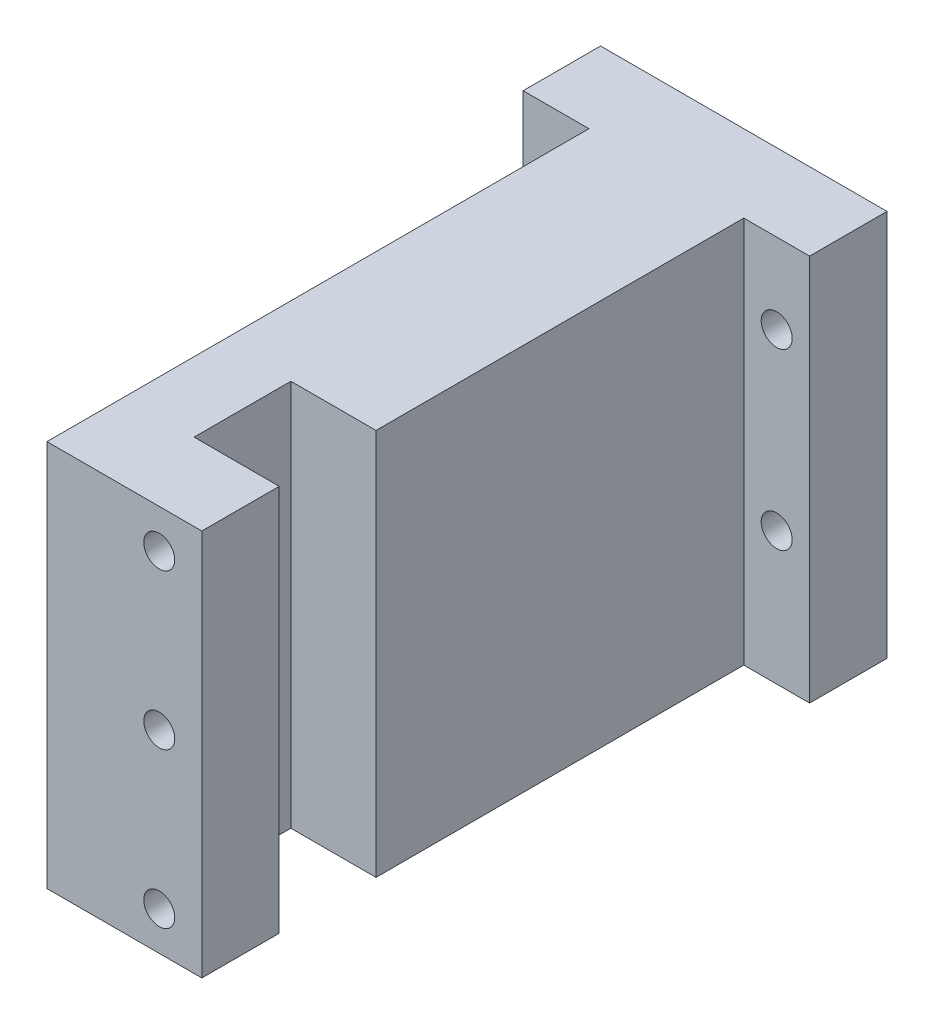
from build123d import *

# Parameters (mm, degrees)
SZKIC1_W                    = 74
SZKIC1_H                    = 100
DODANIE_WYCI_GNI_CIE1_DEPTH = 20
SZKIC3_W                    = 40
SZKIC3_H                    = 100
DODANIE_WYCI_GNI_CIE2_DEPTH = 140
SZKIC4_R                    = 4
WYTNIJ_WYCI_GNI_CIE1_DEPTH  = 20
SZYK_LINIOWY1_COUNT         = 2
SZYK_LINIOWY1_PITCH         = 45
SZYK_LINIOWY1_COUNT_DIR2    = 2
SZYK_LINIOWY1_PITCH_DIR2    = 57
SZKIC5_W                    = 22
SZKIC5_H                    = 25
WYTNIJ_WYCI_GNI_CIE2_DEPTH  = 100
SZKIC6_R                    = 4
WYTNIJ_WYCI_GNI_CIE3_DEPTH  = 10


with BuildPart() as part:
    # Szkic1 → Dodanie-wyciągnięcie1 (new body)
    with BuildSketch(Plane.XY):
        Rectangle(SZKIC1_W, SZKIC1_H)
    extrude(amount=DODANIE_WYCI_GNI_CIE1_DEPTH)

    # Szkic3 → Dodanie-wyciągnięcie2 (add)
    with BuildSketch(Plane.XY.offset(20)):
        Rectangle(SZKIC3_W, SZKIC3_H)
    extrude(amount=DODANIE_WYCI_GNI_CIE2_DEPTH)

    # Szkic4 → Wytnij-wyciągnięcie1 (cut)
    with BuildSketch(Plane.XY.offset(20)):
        with Locations((-28.5, 29.3)):
            Circle(SZKIC4_R)
    wytnij_wyci_gni_cie1 = extrude(amount=-WYTNIJ_WYCI_GNI_CIE1_DEPTH, mode=Mode.SUBTRACT)

    # Szyk liniowy1: Wytnij-wyci_gni_cie1 2 × 2
    with Locations(*[(j * SZYK_LINIOWY1_PITCH_DIR2, -i * SZYK_LINIOWY1_PITCH, 0) for i in range(SZYK_LINIOWY1_COUNT) for j in range(SZYK_LINIOWY1_COUNT_DIR2) if (i, j) != (0, 0)]):
        add(wytnij_wyci_gni_cie1, mode=Mode.SUBTRACT)

    # Szkic5 → Wytnij-wyciągnięcie2 (cut)
    with BuildSketch(Plane(origin=(0, 50, 0), x_dir=(1, 0, 0), z_dir=(0, 1, 0))):
        with Locations((9, -127.5)):
            Rectangle(SZKIC5_W, SZKIC5_H)
    extrude(amount=-WYTNIJ_WYCI_GNI_CIE2_DEPTH, mode=Mode.SUBTRACT)

    # Szkic6 → Wytnij-wyciągnięcie3 (cut)
    with BuildSketch(Plane.XY.offset(160)):
        with Locations((9, 40)):
            Circle(SZKIC6_R)
        with Locations((9, 0)):
            Circle(SZKIC6_R)
        with Locations((9, -40)):
            Circle(SZKIC6_R)
    extrude(amount=-WYTNIJ_WYCI_GNI_CIE3_DEPTH, mode=Mode.SUBTRACT)


solid = part.part
